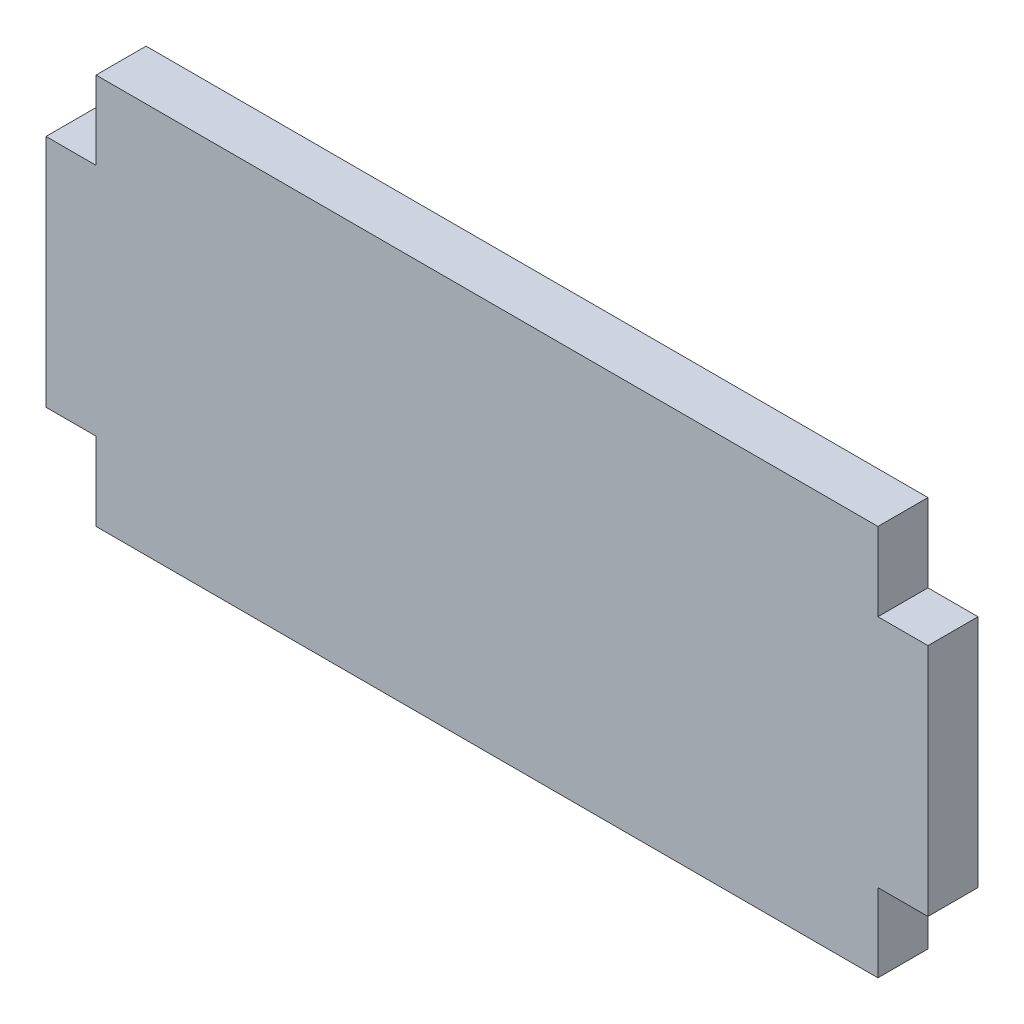
from build123d import *

# Parameters (mm, degrees)
BOSS_EXTRUDE1_DEPTH = 3.2


with BuildPart() as part:
    # Sketch1 → Boss-Extrude1 (new body)
    with BuildSketch(Plane.XY):
        Polygon((0, 0), (0, -15), (3.2, -15), (3.2, -20), (53.2, -20), (53.2, -15), (56.4, -15), (56.4, 0), (53.2, 0), (53.2, 5), (3.2, 5), (3.2, 0), align=None)
    extrude(amount=BOSS_EXTRUDE1_DEPTH)


solid = part.part
